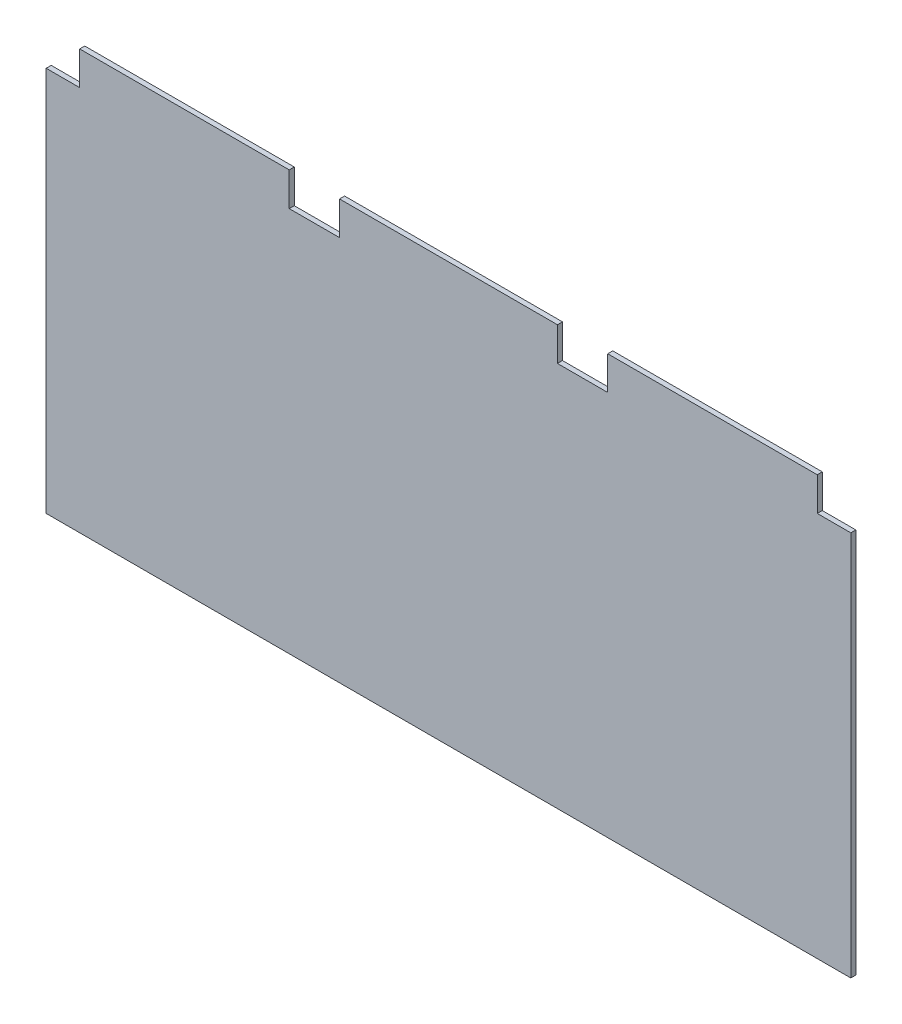
from build123d import *

# Parameters (mm, degrees)
CROQUIS1_W              = 500
CROQUIS1_H              = 260
SALIENTE_EXTRUIR1_DEPTH = 3
CROQUIS2_W              = 30
CROQUIS2_H              = 30
CORTAR_EXTRUIR1_DEPTH   = 4
CORTAR_EXTRUIR2_DEPTH   = 4


with BuildPart() as part:
    # Croquis1 → Saliente-Extruir1 (new body)
    with BuildSketch(Plane.XY):
        Rectangle(CROQUIS1_W, CROQUIS1_H)
    extrude(amount=SALIENTE_EXTRUIR1_DEPTH)

    # Croquis2 → Cortar-Extruir1 (cut, through all)
    with BuildSketch(Plane.XY.offset(3)):
        with Locations((-80, 115)):
            Rectangle(CROQUIS2_W, CROQUIS2_H)
        with Locations((-235, 115)):
            Rectangle(CROQUIS2_W, CROQUIS2_H)
    cortar_extruir1 = extrude(amount=-CORTAR_EXTRUIR1_DEPTH, mode=Mode.SUBTRACT)

    # Simetría1: Cortar-Extruir1 across plane
    add(cortar_extruir1.mirror(Plane(origin=(0, 0, 0), x_dir=(0, 0, 1), z_dir=(1, 0, 0))), mode=Mode.SUBTRACT)

    # Croquis3 → Cortar-Extruir2 (cut, through all)
    with BuildSketch(Plane.XY.offset(3)):
        Polygon((-250, -130), (-240, -130), (-240, 120), (0, 120), (0, 130), (-240, 130), (-250, 130), align=None)
    cortar_extruir2 = extrude(amount=-CORTAR_EXTRUIR2_DEPTH, mode=Mode.SUBTRACT)

    # Simetría2: Cortar-Extruir2 across plane
    add(cortar_extruir2.mirror(Plane(origin=(0, 0, 0), x_dir=(0, 0, 1), z_dir=(1, 0, 0))), mode=Mode.SUBTRACT)


solid = part.part
